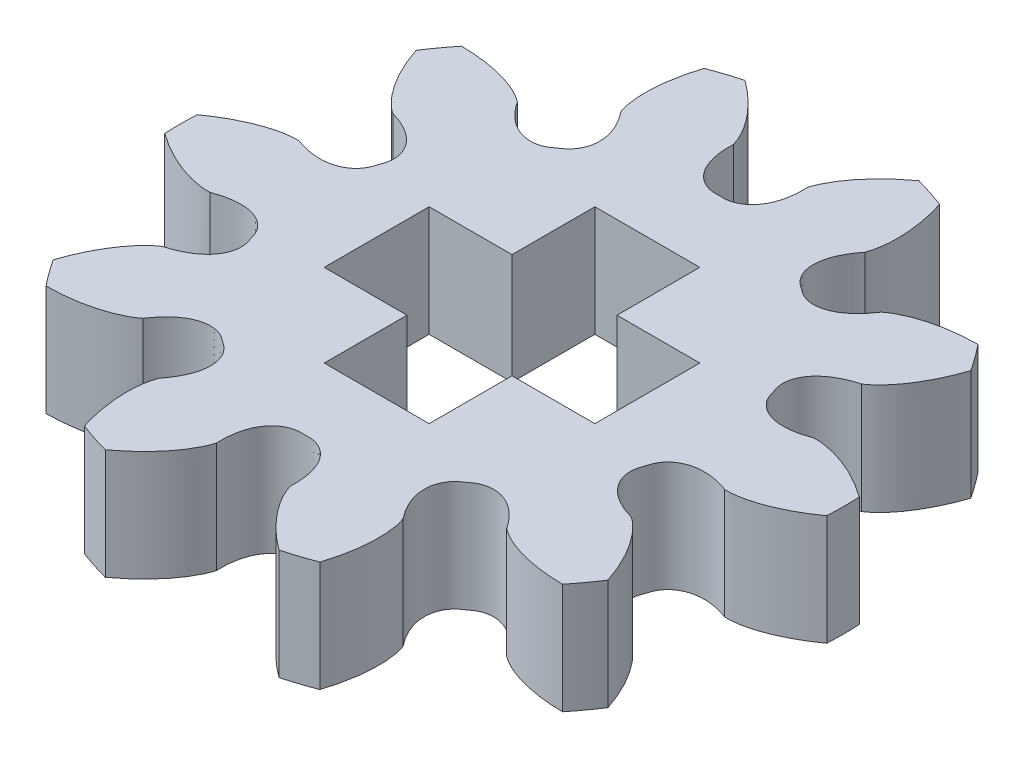
from build123d import *

# Parameters (mm, degrees)
BOSS_EXTRUDE1_DEPTH = 2


with BuildPart() as part:
    # Sketch1 → Boss-Extrude1 (new body)
    with BuildSketch(Plane(origin=(0, 0, 0), x_dir=(1, 0, 0), z_dir=(0, 1, 0))):
        with BuildLine():
            ThreePointArc((-2.131306836, -5.60870138), (-1.854101966, -5.706339098), (-1.572448505, -5.790285459))
            add(Edge.make_bspline(
                [(-1.572448505, -5.790285459), (-1.524121757, -5.753776421), (-1.427468014, -5.680758158), (-1.29005992, -5.561733251), (-1.159069112, -5.435753819), (-1.036126032, -5.301847985), (-0.92251263, -5.159932716), (-0.837301737, -5.034588255), (-0.776335293, -4.929887877), (-0.735125884, -4.848929659), (-0.698268351, -4.765746753), (-0.680638314, -4.707778502), (-0.671824783, -4.678799267)],
                knots=[0, 0, 0, 0, 0.010251706, 0.020503464, 0.030755047, 0.041006321, 0.051257106, 0.061507029, 0.066633012, 0.071758798, 0.07688417, 0.082007812, 0.082007812, 0.082007812, 0.082007812], degree=3, weights=[1, 1, 1, 1, 1, 1, 1, 1, 1, 1, 1, 1, 1]))
            add(Edge.make_bspline(
                [(-0.671824783, -4.678799267), (-0.672788438, -4.651496326), (-0.674715723, -4.596891171), (-0.67266211, -4.514929148), (-0.666126837, -4.433177326), (-0.653115793, -4.352246289), (-0.637164096, -4.271797271), (-0.612712294, -4.193474838), (-0.58299038, -4.117042318), (-0.545673731, -4.043909177), (-0.500291897, -3.975487721), (-0.447276365, -3.912783717), (-0.386261642, -3.857704877), (-0.317525574, -3.812703152), (-0.243061735, -3.777838125), (-0.176887172, -3.760110426), (-0.122948454, -3.751154668), (-0.068263798, -3.749181842), (0, -3.750545471), (0.068263798, -3.749181842), (0.122948454, -3.751154668), (0.176887172, -3.760110426), (0.243061735, -3.777838125), (0.317525574, -3.812703152), (0.386261642, -3.857704877), (0.447276365, -3.912783717), (0.500291897, -3.975487721), (0.545673731, -4.043909177), (0.58299038, -4.117042318), (0.612712294, -4.193474838), (0.637164096, -4.271797271), (0.653115793, -4.352246289), (0.666126837, -4.433177326), (0.67266211, -4.514929148), (0.674715723, -4.596891171), (0.672788438, -4.651496326), (0.671824783, -4.678799267)],
                knots=[0, 0, 0, 0, 0.003643402, 0.007286706, 0.010929975, 0.01457286, 0.01821558, 0.021858686, 0.025500936, 0.029144127, 0.032787024, 0.036428762, 0.040069815, 0.043709849, 0.04734977, 0.050988094, 0.052810356, 0.054631699, 0.058275045, 0.061918391, 0.063739733, 0.065561995, 0.069200319, 0.07284024, 0.076480275, 0.080121327, 0.083763065, 0.087405962, 0.091049153, 0.094691403, 0.098334509, 0.101977229, 0.105620114, 0.109263383, 0.112906688, 0.116550089, 0.116550089, 0.116550089, 0.116550089], degree=3, weights=[1, 1, 1, 1, 1, 1, 1, 1, 1, 1, 1, 1, 1, 1, 1, 1, 1, 1, 1, 1, 1, 1, 1, 1, 1, 1, 1, 1, 1, 1, 1, 1, 1, 1, 1, 1, 1]))
            add(Edge.make_bspline(
                [(0.671824783, -4.678799267), (0.680638314, -4.707778502), (0.698268351, -4.765746753), (0.735125884, -4.848929659), (0.776335293, -4.929887877), (0.837301737, -5.034588255), (0.92251263, -5.159932716), (1.036126032, -5.301847985), (1.159069112, -5.435753819), (1.29005992, -5.561733251), (1.427468014, -5.680758158), (1.524121757, -5.753776421), (1.572448505, -5.790285459)],
                knots=[0, 0, 0, 0, 0.002373455, 0.004747711, 0.007122158, 0.009496697, 0.014244829, 0.01899336, 0.023742117, 0.028491018, 0.03324, 0.037988957, 0.037988957, 0.037988957, 0.037988957], degree=3, weights=[1, 1, 1, 1, 1, 1, 1, 1, 1, 1, 1, 1, 1]))
            ThreePointArc((1.572448505, -5.790285459), (1.854101966, -5.706339098), (2.131306836, -5.60870138))
            add(Edge.make_bspline(
                [(2.131306836, -5.60870138), (2.148944522, -5.550759198), (2.184219984, -5.434874537), (2.225424383, -5.257814913), (2.25734932, -5.078900947), (2.278104487, -4.898304722), (2.286603958, -4.716712576), (2.281865393, -4.565221071), (2.269646944, -4.444681509), (2.25540001, -4.354962652), (2.236324695, -4.266001953), (2.216514811, -4.208741977), (2.206611541, -4.180116819)],
                knots=[0, 0, 0, 0, 0.018166013, 0.036332118, 0.054497913, 0.072663161, 0.090827541, 0.108990394, 0.11807363, 0.127156519, 0.136238672, 0.145317761, 0.145317761, 0.145317761, 0.145317761], degree=3, weights=[1, 1, 1, 1, 1, 1, 1, 1, 1, 1, 1, 1, 1]))
            add(Edge.make_bspline(
                [(2.206611541, -4.180116819), (2.189783662, -4.158594699), (2.156128351, -4.11555103), (2.10961369, -4.048035277), (2.066848322, -3.978055327), (2.029804408, -3.904933043), (1.995422855, -3.830472247), (1.969168007, -3.75273566), (1.948287632, -3.673430349), (1.935490854, -3.592330219), (1.931988406, -3.510301326), (1.938022384, -3.428410974), (1.955009802, -3.347987702), (1.984167098, -3.271178494), (2.023916461, -3.199203349), (2.067032727, -3.145964907), (2.105406004, -3.107015163), (2.148487222, -3.073276279), (2.204515316, -3.034255025), (2.258940368, -2.993027372), (2.304340782, -2.962480587), (2.353242184, -2.938021565), (2.41719861, -2.913467142), (2.49793427, -2.897904795), (2.579994267, -2.893909908), (2.661730745, -2.902606072), (2.7414777, -2.922172928), (2.818409497, -2.950852276), (2.891585883, -2.988084054), (2.960557324, -3.032449159), (3.026376018, -3.08144093), (3.086567959, -3.137149381), (3.144664185, -3.194976265), (3.198003847, -3.257273541), (3.247841323, -3.322375128), (3.278378222, -3.367684455), (3.293646874, -3.39033942)],
                knots=[0, 0, 0, 0, 0.008194405, 0.016388591, 0.024582696, 0.03277594, 0.040968812, 0.04916255, 0.057354364, 0.065548295, 0.073741565, 0.081932227, 0.090121349, 0.09830818, 0.106494756, 0.114677741, 0.118776206, 0.122872602, 0.131066881, 0.139261161, 0.143357557, 0.147456021, 0.155639006, 0.163825582, 0.172012413, 0.180201535, 0.188392198, 0.196585467, 0.204779398, 0.212971212, 0.221164951, 0.229357823, 0.237551066, 0.245745171, 0.253939358, 0.262133762, 0.262133762, 0.262133762, 0.262133762], degree=3, weights=[1, 1, 1, 1, 1, 1, 1, 1, 1, 1, 1, 1, 1, 1, 1, 1, 1, 1, 1, 1, 1, 1, 1, 1, 1, 1, 1, 1, 1, 1, 1, 1, 1, 1, 1, 1, 1]))
            add(Edge.make_bspline(
                [(3.293646874, -3.39033942), (3.317810738, -3.408603651), (3.36614662, -3.445138275), (3.444858677, -3.490770346), (3.525783835, -3.532044637), (3.636648062, -3.580913845), (3.779260749, -3.632233938), (3.954591624, -3.68026552), (4.132762539, -3.716333486), (4.312785181, -3.741258522), (4.493911749, -3.756785244), (4.615025328, -3.759046615), (4.675581963, -3.760177297)],
                knots=[0, 0, 0, 0, 0.009079089, 0.018161243, 0.027244131, 0.036327367, 0.05449022, 0.072654601, 0.090819848, 0.108985643, 0.127151749, 0.145317761, 0.145317761, 0.145317761, 0.145317761], degree=3, weights=[1, 1, 1, 1, 1, 1, 1, 1, 1, 1, 1, 1, 1]))
            ThreePointArc((4.675581963, -3.760177297), (4.854101966, -3.526711514), (5.020975406, -3.284784006))
            add(Edge.make_bspline(
                [(5.020975406, -3.284784006), (5.001187034, -3.227540624), (4.961610188, -3.113053568), (4.890872211, -2.945589986), (4.811537037, -2.782080539), (4.722176522, -2.623775544), (4.622315553, -2.471868547), (4.529437501, -2.352094604), (4.448701191, -2.261757874), (4.384439758, -2.197547932), (4.316717717, -2.136789403), (4.267034616, -2.102109067), (4.242197256, -2.084771824)],
                knots=[0, 0, 0, 0, 0.018166013, 0.036332118, 0.054497913, 0.072663161, 0.090827541, 0.108990394, 0.11807363, 0.127156519, 0.136238672, 0.145317761, 0.145317761, 0.145317761, 0.145317761], degree=3, weights=[1, 1, 1, 1, 1, 1, 1, 1, 1, 1, 1, 1, 1]))
            add(Edge.make_bspline(
                [(4.242197256, -2.084771824), (4.215932831, -2.077251242), (4.163404679, -2.062210278), (4.086088763, -2.034929518), (4.010357671, -2.003451402), (3.937408315, -1.966068098), (3.865826097, -1.926037018), (3.798893059, -1.87857901), (3.735385989, -1.826692843), (3.677363718, -1.768603217), (3.626314804, -1.704299135), (3.583062453, -1.634501765), (3.54953395, -1.559453018), (3.527975379, -1.480174835), (3.51782736, -1.39858163), (3.521416381, -1.33016772), (3.529566929, -1.27610147), (3.544589148, -1.223483634), (3.56698071, -1.158982289), (3.586778496, -1.093638174), (3.605553252, -1.042239612), (3.630738665, -0.993708325), (3.668047774, -0.936250736), (3.724216976, -0.876205302), (3.788256773, -0.824739715), (3.859494449, -0.783731563), (3.935512201, -0.752687398), (4.01460863, -0.730670102), (4.095693859, -0.717779242), (4.177570082, -0.71313097), (4.259615165, -0.714078888), (4.341056073, -0.723768037), (4.422046697, -0.736402864), (4.50181681, -0.755450152), (4.580401928, -0.778824708), (4.631738953, -0.797531586), (4.657407806, -0.806885149)],
                knots=[0, 0, 0, 0, 0.008194405, 0.016388591, 0.024582696, 0.03277594, 0.040968812, 0.04916255, 0.057354364, 0.065548295, 0.073741565, 0.081932227, 0.090121349, 0.09830818, 0.106494756, 0.114677741, 0.118776206, 0.122872602, 0.131066881, 0.139261161, 0.143357557, 0.147456021, 0.155639006, 0.163825582, 0.172012413, 0.180201535, 0.188392198, 0.196585467, 0.204779398, 0.212971212, 0.221164951, 0.229357823, 0.237551066, 0.245745171, 0.253939358, 0.262133762, 0.262133762, 0.262133762, 0.262133762], degree=3, weights=[1, 1, 1, 1, 1, 1, 1, 1, 1, 1, 1, 1, 1, 1, 1, 1, 1, 1, 1, 1, 1, 1, 1, 1, 1, 1, 1, 1, 1, 1, 1, 1, 1, 1, 1, 1, 1]))
            add(Edge.make_bspline(
                [(4.657407806, -0.806885149), (4.687692228, -0.807458059), (4.748271292, -0.808604072), (4.838772541, -0.799255407), (4.928502789, -0.785080395), (5.046918433, -0.759452057), (5.192459714, -0.717145251), (5.362537627, -0.652946714), (5.527881144, -0.577400075), (5.688173089, -0.491750199), (5.843833939, -0.397848055), (5.943146083, -0.328488767), (5.992802028, -0.293809212)],
                knots=[0, 0, 0, 0, 0.009079089, 0.018161243, 0.027244131, 0.036327367, 0.05449022, 0.072654601, 0.090819848, 0.108985643, 0.127151749, 0.145317761, 0.145317761, 0.145317761, 0.145317761], degree=3, weights=[1, 1, 1, 1, 1, 1, 1, 1, 1, 1, 1, 1, 1]))
            ThreePointArc((5.992802028, -0.293809212), (6, 0), (5.992802028, 0.293809212))
            add(Edge.make_bspline(
                [(5.992802028, 0.293809212), (5.943146083, 0.328488767), (5.843833939, 0.397848055), (5.688173089, 0.491750199), (5.527881144, 0.577400075), (5.362537627, 0.652946714), (5.192459714, 0.717145251), (5.046918433, 0.759452057), (4.928502789, 0.785080395), (4.838772541, 0.799255407), (4.748271292, 0.808604072), (4.687692228, 0.807458059), (4.657407806, 0.806885149)],
                knots=[0, 0, 0, 0, 0.018166013, 0.036332118, 0.054497913, 0.072663161, 0.090827541, 0.108990394, 0.11807363, 0.127156519, 0.136238672, 0.145317761, 0.145317761, 0.145317761, 0.145317761], degree=3, weights=[1, 1, 1, 1, 1, 1, 1, 1, 1, 1, 1, 1, 1]))
            add(Edge.make_bspline(
                [(4.657407806, 0.806885149), (4.631738953, 0.797531586), (4.580401928, 0.778824708), (4.50181681, 0.755450152), (4.422046697, 0.736402864), (4.341056073, 0.723768037), (4.259615165, 0.714078888), (4.177570082, 0.71313097), (4.095693859, 0.717779242), (4.01460863, 0.730670102), (3.935512201, 0.752687398), (3.859494449, 0.783731563), (3.788256773, 0.824739715), (3.724216976, 0.876205302), (3.668047774, 0.936250736), (3.630738665, 0.993708325), (3.605553252, 1.042239612), (3.586778496, 1.093638174), (3.56698071, 1.158982289), (3.544589148, 1.223483634), (3.529566929, 1.27610147), (3.521416381, 1.33016772), (3.51782736, 1.39858163), (3.527975379, 1.480174835), (3.54953395, 1.559453018), (3.583062453, 1.634501765), (3.626314804, 1.704299135), (3.677363718, 1.768603217), (3.735385989, 1.826692843), (3.798893059, 1.87857901), (3.865826097, 1.926037018), (3.937408315, 1.966068098), (4.010357671, 2.003451402), (4.086088763, 2.034929518), (4.163404679, 2.062210278), (4.215932831, 2.077251242), (4.242197256, 2.084771824)],
                knots=[0, 0, 0, 0, 0.008194405, 0.016388591, 0.024582696, 0.03277594, 0.040968812, 0.04916255, 0.057354364, 0.065548295, 0.073741565, 0.081932227, 0.090121349, 0.09830818, 0.106494756, 0.114677741, 0.118776206, 0.122872602, 0.131066881, 0.139261161, 0.143357557, 0.147456021, 0.155639006, 0.163825582, 0.172012413, 0.180201535, 0.188392198, 0.196585467, 0.204779398, 0.212971212, 0.221164951, 0.229357823, 0.237551066, 0.245745171, 0.253939358, 0.262133762, 0.262133762, 0.262133762, 0.262133762], degree=3, weights=[1, 1, 1, 1, 1, 1, 1, 1, 1, 1, 1, 1, 1, 1, 1, 1, 1, 1, 1, 1, 1, 1, 1, 1, 1, 1, 1, 1, 1, 1, 1, 1, 1, 1, 1, 1, 1]))
            add(Edge.make_bspline(
                [(4.242197256, 2.084771824), (4.267034616, 2.102109067), (4.316717717, 2.136789403), (4.384439758, 2.197547932), (4.448701191, 2.261757874), (4.529437501, 2.352094604), (4.622315553, 2.471868547), (4.722176522, 2.623775544), (4.811537037, 2.782080539), (4.890872211, 2.945589986), (4.961610188, 3.113053568), (5.001187034, 3.227540624), (5.020975406, 3.284784006)],
                knots=[0, 0, 0, 0, 0.009079089, 0.018161243, 0.027244131, 0.036327367, 0.05449022, 0.072654601, 0.090819848, 0.108985643, 0.127151749, 0.145317761, 0.145317761, 0.145317761, 0.145317761], degree=3, weights=[1, 1, 1, 1, 1, 1, 1, 1, 1, 1, 1, 1, 1]))
            ThreePointArc((5.020975406, 3.284784006), (4.854101966, 3.526711514), (4.675581963, 3.760177297))
            add(Edge.make_bspline(
                [(4.675581963, 3.760177297), (4.615025328, 3.759046615), (4.493911749, 3.756785244), (4.312785181, 3.741258522), (4.132762539, 3.716333486), (3.954591624, 3.68026552), (3.779260749, 3.632233938), (3.636648062, 3.580913845), (3.525783835, 3.532044637), (3.444858677, 3.490770346), (3.36614662, 3.445138275), (3.317810738, 3.408603651), (3.293646874, 3.39033942)],
                knots=[0, 0, 0, 0, 0.018166013, 0.036332118, 0.054497913, 0.072663161, 0.090827541, 0.108990394, 0.11807363, 0.127156519, 0.136238672, 0.145317761, 0.145317761, 0.145317761, 0.145317761], degree=3, weights=[1, 1, 1, 1, 1, 1, 1, 1, 1, 1, 1, 1, 1]))
            add(Edge.make_bspline(
                [(3.293646874, 3.39033942), (3.278378222, 3.367684455), (3.247841323, 3.322375128), (3.198003847, 3.257273541), (3.144664185, 3.194976265), (3.086567959, 3.137149381), (3.026376018, 3.08144093), (2.960557324, 3.032449159), (2.891585883, 2.988084054), (2.818409497, 2.950852276), (2.7414777, 2.922172928), (2.661730745, 2.902606072), (2.579994267, 2.893909908), (2.49793427, 2.897904795), (2.41719861, 2.913467142), (2.353242184, 2.938021565), (2.304340782, 2.962480587), (2.258940368, 2.993027372), (2.204515316, 3.034255025), (2.148487222, 3.073276279), (2.105406004, 3.107015163), (2.067032727, 3.145964907), (2.023916461, 3.199203349), (1.984167098, 3.271178494), (1.955009802, 3.347987702), (1.938022384, 3.428410974), (1.931988406, 3.510301326), (1.935490854, 3.592330219), (1.948287632, 3.673430349), (1.969168007, 3.75273566), (1.995422855, 3.830472247), (2.029804408, 3.904933043), (2.066848322, 3.978055327), (2.10961369, 4.048035277), (2.156128351, 4.11555103), (2.189783662, 4.158594699), (2.206611541, 4.180116819)],
                knots=[0, 0, 0, 0, 0.008194405, 0.016388591, 0.024582696, 0.03277594, 0.040968812, 0.04916255, 0.057354364, 0.065548295, 0.073741565, 0.081932227, 0.090121349, 0.09830818, 0.106494756, 0.114677741, 0.118776206, 0.122872602, 0.131066881, 0.139261161, 0.143357557, 0.147456021, 0.155639006, 0.163825582, 0.172012413, 0.180201535, 0.188392198, 0.196585467, 0.204779398, 0.212971212, 0.221164951, 0.229357823, 0.237551066, 0.245745171, 0.253939358, 0.262133762, 0.262133762, 0.262133762, 0.262133762], degree=3, weights=[1, 1, 1, 1, 1, 1, 1, 1, 1, 1, 1, 1, 1, 1, 1, 1, 1, 1, 1, 1, 1, 1, 1, 1, 1, 1, 1, 1, 1, 1, 1, 1, 1, 1, 1, 1, 1]))
            add(Edge.make_bspline(
                [(2.206611541, 4.180116819), (2.216514811, 4.208741977), (2.236324695, 4.266001953), (2.25540001, 4.354962652), (2.269646944, 4.444681509), (2.281865393, 4.565221071), (2.286603958, 4.716712576), (2.278104487, 4.898304722), (2.25734932, 5.078900947), (2.225424383, 5.257814913), (2.184219984, 5.434874537), (2.148944522, 5.550759198), (2.131306836, 5.60870138)],
                knots=[0, 0, 0, 0, 0.009079089, 0.018161243, 0.027244131, 0.036327367, 0.05449022, 0.072654601, 0.090819848, 0.108985643, 0.127151749, 0.145317761, 0.145317761, 0.145317761, 0.145317761], degree=3, weights=[1, 1, 1, 1, 1, 1, 1, 1, 1, 1, 1, 1, 1]))
            ThreePointArc((2.131306836, 5.60870138), (1.854101966, 5.706339098), (1.572448505, 5.790285459))
            add(Edge.make_bspline(
                [(1.572448505, 5.790285459), (1.524121757, 5.753776421), (1.427468014, 5.680758158), (1.29005992, 5.561733251), (1.159069112, 5.435753819), (1.036126032, 5.301847985), (0.92251263, 5.159932716), (0.837301737, 5.034588255), (0.776335293, 4.929887877), (0.735125884, 4.848929659), (0.698268351, 4.765746753), (0.680638314, 4.707778502), (0.671824783, 4.678799267)],
                knots=[0, 0, 0, 0, 0.018166013, 0.036332118, 0.054497913, 0.072663161, 0.090827541, 0.108990394, 0.11807363, 0.127156519, 0.136238672, 0.145317761, 0.145317761, 0.145317761, 0.145317761], degree=3, weights=[1, 1, 1, 1, 1, 1, 1, 1, 1, 1, 1, 1, 1]))
            add(Edge.make_bspline(
                [(0.671824783, 4.678799267), (0.672788438, 4.651496326), (0.674715723, 4.596891171), (0.67266211, 4.514929148), (0.666126837, 4.433177326), (0.653115793, 4.352246289), (0.637164096, 4.271797271), (0.612712294, 4.193474838), (0.58299038, 4.117042318), (0.545673731, 4.043909177), (0.500291897, 3.975487721), (0.447276365, 3.912783717), (0.386261642, 3.857704877), (0.317525574, 3.812703152), (0.243061735, 3.777838125), (0.176887172, 3.760110426), (0.122948454, 3.751154668), (0.068263798, 3.749181842), (0, 3.750545471), (-0.068263798, 3.749181842), (-0.122948454, 3.751154668), (-0.176887172, 3.760110426), (-0.243061735, 3.777838125), (-0.317525574, 3.812703152), (-0.386261642, 3.857704877), (-0.447276365, 3.912783717), (-0.500291897, 3.975487721), (-0.545673731, 4.043909177), (-0.58299038, 4.117042318), (-0.612712294, 4.193474838), (-0.637164096, 4.271797271), (-0.653115793, 4.352246289), (-0.666126837, 4.433177326), (-0.67266211, 4.514929148), (-0.674715723, 4.596891171), (-0.672788438, 4.651496326), (-0.671824783, 4.678799267)],
                knots=[0, 0, 0, 0, 0.008194405, 0.016388591, 0.024582696, 0.03277594, 0.040968812, 0.04916255, 0.057354364, 0.065548295, 0.073741565, 0.081932227, 0.090121349, 0.09830818, 0.106494756, 0.114677741, 0.118776206, 0.122872602, 0.131066881, 0.139261161, 0.143357557, 0.147456021, 0.155639006, 0.163825582, 0.172012413, 0.180201535, 0.188392198, 0.196585467, 0.204779398, 0.212971212, 0.221164951, 0.229357823, 0.237551066, 0.245745171, 0.253939358, 0.262133762, 0.262133762, 0.262133762, 0.262133762], degree=3, weights=[1, 1, 1, 1, 1, 1, 1, 1, 1, 1, 1, 1, 1, 1, 1, 1, 1, 1, 1, 1, 1, 1, 1, 1, 1, 1, 1, 1, 1, 1, 1, 1, 1, 1, 1, 1, 1]))
            add(Edge.make_bspline(
                [(-0.671824783, 4.678799267), (-0.680638314, 4.707778502), (-0.698268351, 4.765746753), (-0.735125884, 4.848929659), (-0.776335293, 4.929887877), (-0.837301737, 5.034588255), (-0.92251263, 5.159932716), (-1.036126032, 5.301847985), (-1.159069112, 5.435753819), (-1.29005992, 5.561733251), (-1.427468014, 5.680758158), (-1.524121757, 5.753776421), (-1.572448505, 5.790285459)],
                knots=[0, 0, 0, 0, 0.009079089, 0.018161243, 0.027244131, 0.036327367, 0.05449022, 0.072654601, 0.090819848, 0.108985643, 0.127151749, 0.145317761, 0.145317761, 0.145317761, 0.145317761], degree=3, weights=[1, 1, 1, 1, 1, 1, 1, 1, 1, 1, 1, 1, 1]))
            ThreePointArc((-1.572448505, 5.790285459), (-1.854101966, 5.706339098), (-2.131306836, 5.60870138))
            add(Edge.make_bspline(
                [(-2.131306836, 5.60870138), (-2.148944522, 5.550759198), (-2.184219984, 5.434874537), (-2.225424383, 5.257814913), (-2.25734932, 5.078900947), (-2.278104487, 4.898304722), (-2.286603958, 4.716712576), (-2.281865393, 4.565221071), (-2.269646944, 4.444681509), (-2.25540001, 4.354962652), (-2.236324695, 4.266001953), (-2.216514811, 4.208741977), (-2.206611541, 4.180116819)],
                knots=[0, 0, 0, 0, 0.018166013, 0.036332118, 0.054497913, 0.072663161, 0.090827541, 0.108990394, 0.11807363, 0.127156519, 0.136238672, 0.145317761, 0.145317761, 0.145317761, 0.145317761], degree=3, weights=[1, 1, 1, 1, 1, 1, 1, 1, 1, 1, 1, 1, 1]))
            add(Edge.make_bspline(
                [(-2.206611541, 4.180116819), (-2.189783662, 4.158594699), (-2.156128351, 4.11555103), (-2.10961369, 4.048035277), (-2.066848322, 3.978055327), (-2.029804408, 3.904933043), (-1.995422855, 3.830472247), (-1.969168007, 3.75273566), (-1.948287632, 3.673430349), (-1.935490854, 3.592330219), (-1.931988406, 3.510301326), (-1.938022384, 3.428410974), (-1.955009802, 3.347987702), (-1.984167098, 3.271178494), (-2.023916461, 3.199203349), (-2.067032727, 3.145964907), (-2.105406004, 3.107015163), (-2.148487222, 3.073276279), (-2.204515316, 3.034255025), (-2.258940368, 2.993027372), (-2.304340782, 2.962480587), (-2.353242184, 2.938021565), (-2.41719861, 2.913467142), (-2.49793427, 2.897904795), (-2.579994267, 2.893909908), (-2.661730745, 2.902606072), (-2.7414777, 2.922172928), (-2.818409497, 2.950852276), (-2.891585883, 2.988084054), (-2.960557324, 3.032449159), (-3.026376018, 3.08144093), (-3.086567959, 3.137149381), (-3.144664185, 3.194976265), (-3.198003847, 3.257273541), (-3.247841323, 3.322375128), (-3.278378222, 3.367684455), (-3.293646874, 3.39033942)],
                knots=[0, 0, 0, 0, 0.008194405, 0.016388591, 0.024582696, 0.03277594, 0.040968812, 0.04916255, 0.057354364, 0.065548295, 0.073741565, 0.081932227, 0.090121349, 0.09830818, 0.106494756, 0.114677741, 0.118776206, 0.122872602, 0.131066881, 0.139261161, 0.143357557, 0.147456021, 0.155639006, 0.163825582, 0.172012413, 0.180201535, 0.188392198, 0.196585467, 0.204779398, 0.212971212, 0.221164951, 0.229357823, 0.237551066, 0.245745171, 0.253939358, 0.262133762, 0.262133762, 0.262133762, 0.262133762], degree=3, weights=[1, 1, 1, 1, 1, 1, 1, 1, 1, 1, 1, 1, 1, 1, 1, 1, 1, 1, 1, 1, 1, 1, 1, 1, 1, 1, 1, 1, 1, 1, 1, 1, 1, 1, 1, 1, 1]))
            add(Edge.make_bspline(
                [(-3.293646874, 3.39033942), (-3.317810738, 3.408603651), (-3.36614662, 3.445138275), (-3.444858677, 3.490770346), (-3.525783835, 3.532044637), (-3.636648062, 3.580913845), (-3.779260749, 3.632233938), (-3.954591624, 3.68026552), (-4.132762539, 3.716333486), (-4.312785181, 3.741258522), (-4.493911749, 3.756785244), (-4.615025328, 3.759046615), (-4.675581963, 3.760177297)],
                knots=[0, 0, 0, 0, 0.009079089, 0.018161243, 0.027244131, 0.036327367, 0.05449022, 0.072654601, 0.090819848, 0.108985643, 0.127151749, 0.145317761, 0.145317761, 0.145317761, 0.145317761], degree=3, weights=[1, 1, 1, 1, 1, 1, 1, 1, 1, 1, 1, 1, 1]))
            ThreePointArc((-4.675581963, 3.760177297), (-4.854101966, 3.526711514), (-5.020975406, 3.284784006))
            add(Edge.make_bspline(
                [(-5.020975406, 3.284784006), (-5.001187034, 3.227540624), (-4.961610188, 3.113053568), (-4.890872211, 2.945589986), (-4.811537037, 2.782080539), (-4.722176522, 2.623775544), (-4.622315553, 2.471868547), (-4.529437501, 2.352094604), (-4.448701191, 2.261757874), (-4.384439758, 2.197547932), (-4.316717717, 2.136789403), (-4.267034616, 2.102109067), (-4.242197256, 2.084771824)],
                knots=[0, 0, 0, 0, 0.018166013, 0.036332118, 0.054497913, 0.072663161, 0.090827541, 0.108990394, 0.11807363, 0.127156519, 0.136238672, 0.145317761, 0.145317761, 0.145317761, 0.145317761], degree=3, weights=[1, 1, 1, 1, 1, 1, 1, 1, 1, 1, 1, 1, 1]))
            add(Edge.make_bspline(
                [(-4.242197256, 2.084771824), (-4.215932831, 2.077251242), (-4.163404679, 2.062210278), (-4.086088763, 2.034929518), (-4.010357671, 2.003451402), (-3.937408315, 1.966068098), (-3.865826097, 1.926037018), (-3.798893059, 1.87857901), (-3.735385989, 1.826692843), (-3.677363718, 1.768603217), (-3.626314804, 1.704299135), (-3.583062453, 1.634501765), (-3.54953395, 1.559453018), (-3.527975379, 1.480174835), (-3.51782736, 1.39858163), (-3.521416381, 1.33016772), (-3.529566929, 1.27610147), (-3.544589148, 1.223483634), (-3.56698071, 1.158982289), (-3.586778496, 1.093638174), (-3.605553252, 1.042239612), (-3.630738665, 0.993708325), (-3.668047774, 0.936250736), (-3.724216976, 0.876205302), (-3.788256773, 0.824739715), (-3.859494449, 0.783731563), (-3.935512201, 0.752687398), (-4.01460863, 0.730670102), (-4.095693859, 0.717779242), (-4.177570082, 0.71313097), (-4.259615165, 0.714078888), (-4.341056073, 0.723768037), (-4.422046697, 0.736402864), (-4.50181681, 0.755450152), (-4.580401928, 0.778824708), (-4.631738953, 0.797531586), (-4.657407806, 0.806885149)],
                knots=[0, 0, 0, 0, 0.008194405, 0.016388591, 0.024582696, 0.03277594, 0.040968812, 0.04916255, 0.057354364, 0.065548295, 0.073741565, 0.081932227, 0.090121349, 0.09830818, 0.106494756, 0.114677741, 0.118776206, 0.122872602, 0.131066881, 0.139261161, 0.143357557, 0.147456021, 0.155639006, 0.163825582, 0.172012413, 0.180201535, 0.188392198, 0.196585467, 0.204779398, 0.212971212, 0.221164951, 0.229357823, 0.237551066, 0.245745171, 0.253939358, 0.262133762, 0.262133762, 0.262133762, 0.262133762], degree=3, weights=[1, 1, 1, 1, 1, 1, 1, 1, 1, 1, 1, 1, 1, 1, 1, 1, 1, 1, 1, 1, 1, 1, 1, 1, 1, 1, 1, 1, 1, 1, 1, 1, 1, 1, 1, 1, 1]))
            add(Edge.make_bspline(
                [(-4.657407806, 0.806885149), (-4.687692228, 0.807458059), (-4.748271292, 0.808604072), (-4.838772541, 0.799255407), (-4.928502789, 0.785080395), (-5.046918433, 0.759452057), (-5.192459714, 0.717145251), (-5.362537627, 0.652946714), (-5.527881144, 0.577400075), (-5.688173089, 0.491750199), (-5.843833939, 0.397848055), (-5.943146083, 0.328488767), (-5.992802028, 0.293809212)],
                knots=[0, 0, 0, 0, 0.009079089, 0.018161243, 0.027244131, 0.036327367, 0.05449022, 0.072654601, 0.090819848, 0.108985643, 0.127151749, 0.145317761, 0.145317761, 0.145317761, 0.145317761], degree=3, weights=[1, 1, 1, 1, 1, 1, 1, 1, 1, 1, 1, 1, 1]))
            ThreePointArc((-5.992802028, 0.293809212), (-6, 0), (-5.992802028, -0.293809212))
            add(Edge.make_bspline(
                [(-5.992802028, -0.293809212), (-5.943146083, -0.328488767), (-5.843833939, -0.397848055), (-5.688173089, -0.491750199), (-5.527881144, -0.577400075), (-5.362537627, -0.652946714), (-5.192459714, -0.717145251), (-5.046918433, -0.759452057), (-4.928502789, -0.785080395), (-4.838772541, -0.799255407), (-4.748271292, -0.808604072), (-4.687692228, -0.807458059), (-4.657407806, -0.806885149)],
                knots=[0, 0, 0, 0, 0.018166013, 0.036332118, 0.054497913, 0.072663161, 0.090827541, 0.108990394, 0.11807363, 0.127156519, 0.136238672, 0.145317761, 0.145317761, 0.145317761, 0.145317761], degree=3, weights=[1, 1, 1, 1, 1, 1, 1, 1, 1, 1, 1, 1, 1]))
            add(Edge.make_bspline(
                [(-4.657407806, -0.806885149), (-4.631738953, -0.797531586), (-4.580401928, -0.778824708), (-4.50181681, -0.755450152), (-4.422046697, -0.736402864), (-4.341056073, -0.723768037), (-4.259615165, -0.714078888), (-4.177570082, -0.71313097), (-4.095693859, -0.717779242), (-4.01460863, -0.730670102), (-3.935512201, -0.752687398), (-3.859494449, -0.783731563), (-3.788256773, -0.824739715), (-3.724216976, -0.876205302), (-3.668047774, -0.936250736), (-3.630738665, -0.993708325), (-3.605553252, -1.042239612), (-3.586778496, -1.093638174), (-3.56698071, -1.158982289), (-3.544589148, -1.223483634), (-3.529566929, -1.27610147), (-3.521416381, -1.33016772), (-3.51782736, -1.39858163), (-3.527975379, -1.480174835), (-3.54953395, -1.559453018), (-3.583062453, -1.634501765), (-3.626314804, -1.704299135), (-3.677363718, -1.768603217), (-3.735385989, -1.826692843), (-3.798893059, -1.87857901), (-3.865826097, -1.926037018), (-3.937408315, -1.966068098), (-4.010357671, -2.003451402), (-4.086088763, -2.034929518), (-4.163404679, -2.062210278), (-4.215932831, -2.077251242), (-4.242197256, -2.084771824)],
                knots=[0, 0, 0, 0, 0.008194405, 0.016388591, 0.024582696, 0.03277594, 0.040968812, 0.04916255, 0.057354364, 0.065548295, 0.073741565, 0.081932227, 0.090121349, 0.09830818, 0.106494756, 0.114677741, 0.118776206, 0.122872602, 0.131066881, 0.139261161, 0.143357557, 0.147456021, 0.155639006, 0.163825582, 0.172012413, 0.180201535, 0.188392198, 0.196585467, 0.204779398, 0.212971212, 0.221164951, 0.229357823, 0.237551066, 0.245745171, 0.253939358, 0.262133762, 0.262133762, 0.262133762, 0.262133762], degree=3, weights=[1, 1, 1, 1, 1, 1, 1, 1, 1, 1, 1, 1, 1, 1, 1, 1, 1, 1, 1, 1, 1, 1, 1, 1, 1, 1, 1, 1, 1, 1, 1, 1, 1, 1, 1, 1, 1]))
            add(Edge.make_bspline(
                [(-4.242197256, -2.084771824), (-4.267034616, -2.102109067), (-4.316717717, -2.136789403), (-4.384439758, -2.197547932), (-4.448701191, -2.261757874), (-4.529437501, -2.352094604), (-4.622315553, -2.471868547), (-4.722176522, -2.623775544), (-4.811537037, -2.782080539), (-4.890872211, -2.945589986), (-4.961610188, -3.113053568), (-5.001187034, -3.227540624), (-5.020975406, -3.284784006)],
                knots=[0, 0, 0, 0, 0.009079089, 0.018161243, 0.027244131, 0.036327367, 0.05449022, 0.072654601, 0.090819848, 0.108985643, 0.127151749, 0.145317761, 0.145317761, 0.145317761, 0.145317761], degree=3, weights=[1, 1, 1, 1, 1, 1, 1, 1, 1, 1, 1, 1, 1]))
            ThreePointArc((-5.020975406, -3.284784006), (-4.854101966, -3.526711514), (-4.675581963, -3.760177297))
            add(Edge.make_bspline(
                [(-4.675581963, -3.760177297), (-4.615025328, -3.759046615), (-4.493911749, -3.756785244), (-4.312785181, -3.741258522), (-4.132762539, -3.716333486), (-3.954591624, -3.68026552), (-3.779260749, -3.632233938), (-3.636648062, -3.580913845), (-3.525783835, -3.532044637), (-3.444858677, -3.490770346), (-3.36614662, -3.445138275), (-3.317810738, -3.408603651), (-3.293646874, -3.39033942)],
                knots=[0, 0, 0, 0, 0.018166013, 0.036332118, 0.054497913, 0.072663161, 0.090827541, 0.108990394, 0.11807363, 0.127156519, 0.136238672, 0.145317761, 0.145317761, 0.145317761, 0.145317761], degree=3, weights=[1, 1, 1, 1, 1, 1, 1, 1, 1, 1, 1, 1, 1]))
            add(Edge.make_bspline(
                [(-3.293646874, -3.39033942), (-3.278378222, -3.367684455), (-3.247841323, -3.322375128), (-3.198003847, -3.257273541), (-3.144664185, -3.194976265), (-3.086567959, -3.137149381), (-3.026376018, -3.08144093), (-2.960557324, -3.032449159), (-2.891585883, -2.988084054), (-2.818409497, -2.950852276), (-2.7414777, -2.922172928), (-2.661730745, -2.902606072), (-2.579994267, -2.893909908), (-2.49793427, -2.897904795), (-2.41719861, -2.913467142), (-2.353242184, -2.938021565), (-2.304340782, -2.962480587), (-2.258940368, -2.993027372), (-2.204515316, -3.034255025), (-2.148487222, -3.073276279), (-2.105406004, -3.107015163), (-2.067032727, -3.145964907), (-2.023916461, -3.199203349), (-1.984167098, -3.271178494), (-1.955009802, -3.347987702), (-1.938022384, -3.428410974), (-1.931988406, -3.510301326), (-1.935490854, -3.592330219), (-1.948287632, -3.673430349), (-1.969168007, -3.75273566), (-1.995422855, -3.830472247), (-2.029804408, -3.904933043), (-2.066848322, -3.978055327), (-2.10961369, -4.048035277), (-2.156128351, -4.11555103), (-2.189783662, -4.158594699), (-2.206611541, -4.180116819)],
                knots=[0, 0, 0, 0, 0.008194405, 0.016388591, 0.024582696, 0.03277594, 0.040968812, 0.04916255, 0.057354364, 0.065548295, 0.073741565, 0.081932227, 0.090121349, 0.09830818, 0.106494756, 0.114677741, 0.118776206, 0.122872602, 0.131066881, 0.139261161, 0.143357557, 0.147456021, 0.155639006, 0.163825582, 0.172012413, 0.180201535, 0.188392198, 0.196585467, 0.204779398, 0.212971212, 0.221164951, 0.229357823, 0.237551066, 0.245745171, 0.253939358, 0.262133762, 0.262133762, 0.262133762, 0.262133762], degree=3, weights=[1, 1, 1, 1, 1, 1, 1, 1, 1, 1, 1, 1, 1, 1, 1, 1, 1, 1, 1, 1, 1, 1, 1, 1, 1, 1, 1, 1, 1, 1, 1, 1, 1, 1, 1, 1, 1]))
            add(Edge.make_bspline(
                [(-2.206611541, -4.180116819), (-2.216514811, -4.208741977), (-2.236324695, -4.266001953), (-2.25540001, -4.354962652), (-2.269646944, -4.444681509), (-2.281865393, -4.565221071), (-2.286603958, -4.716712576), (-2.278104487, -4.898304722), (-2.25734932, -5.078900947), (-2.225424383, -5.257814913), (-2.184219984, -5.434874537), (-2.148944522, -5.550759198), (-2.131306836, -5.60870138)],
                knots=[0, 0, 0, 0, 0.009079089, 0.018161243, 0.027244131, 0.036327367, 0.05449022, 0.072654601, 0.090819848, 0.108985643, 0.127151749, 0.145317761, 0.145317761, 0.145317761, 0.145317761], degree=3, weights=[1, 1, 1, 1, 1, 1, 1, 1, 1, 1, 1, 1, 1]))
        make_face()
        Polygon((-2.45, 0.95), (-2.45, -0.95), (-0.95, -0.95), (-0.95, -2.45), (0.95, -2.45), (0.95, -0.95), (2.45, -0.95), (2.45, 0.95), (0.95, 0.95), (0.95, 2.45), (-0.95, 2.45), (-0.95, 0.95), align=None, mode=Mode.SUBTRACT)
    extrude(amount=BOSS_EXTRUDE1_DEPTH)


solid = part.part
